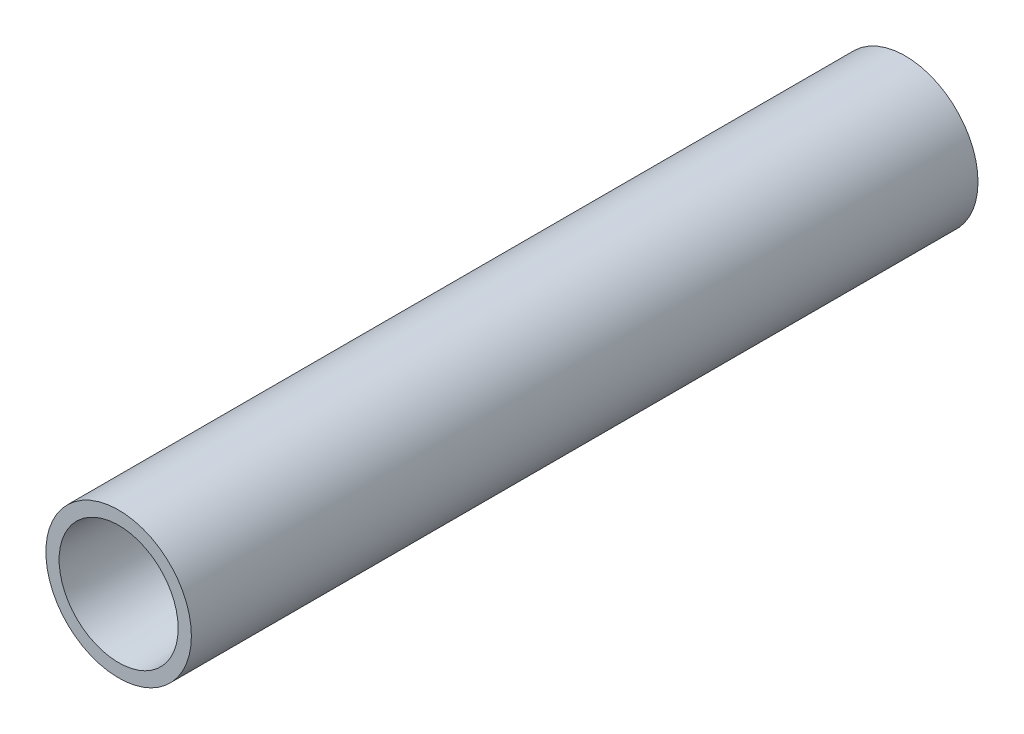
from build123d import *

# Parameters (mm, degrees)
SKETCH1_R           = 2.775
BOSS_EXTRUDE1_DEPTH = 30
SKETCH2_R           = 2.27
CUT_EXTRUDE1_DEPTH  = 5.68
CUT_EXTRUDE1_TAPER  = 3.074
SKETCH7_R           = 1
CUT_EXTRUDE2_DEPTH  = 31
SKETCH9_R           = 2.27
CUT_EXTRUDE3_DEPTH  = 5.68
CUT_EXTRUDE3_TAPER  = 3.074


with BuildPart() as part:
    # Sketch1 → Boss-Extrude1 (new body)
    with BuildSketch(Plane.XY):
        Circle(SKETCH1_R)
    extrude(amount=BOSS_EXTRUDE1_DEPTH)

    # Sketch2 → Cut-Extrude1 (cut)
    with BuildSketch(Plane.XY):
        Circle(SKETCH2_R)
    extrude(amount=CUT_EXTRUDE1_DEPTH, taper=CUT_EXTRUDE1_TAPER, mode=Mode.SUBTRACT)

    # Sketch7 → Cut-Extrude2 (cut, through all)
    with BuildSketch(Plane.XY):
        Circle(SKETCH7_R)
    extrude(amount=CUT_EXTRUDE2_DEPTH, mode=Mode.SUBTRACT)

    # Sketch9 → Cut-Extrude3 (cut)
    with BuildSketch(Plane.XY.offset(30)):
        Circle(SKETCH9_R)
    extrude(amount=-CUT_EXTRUDE3_DEPTH, taper=CUT_EXTRUDE3_TAPER, mode=Mode.SUBTRACT)


solid = part.part
